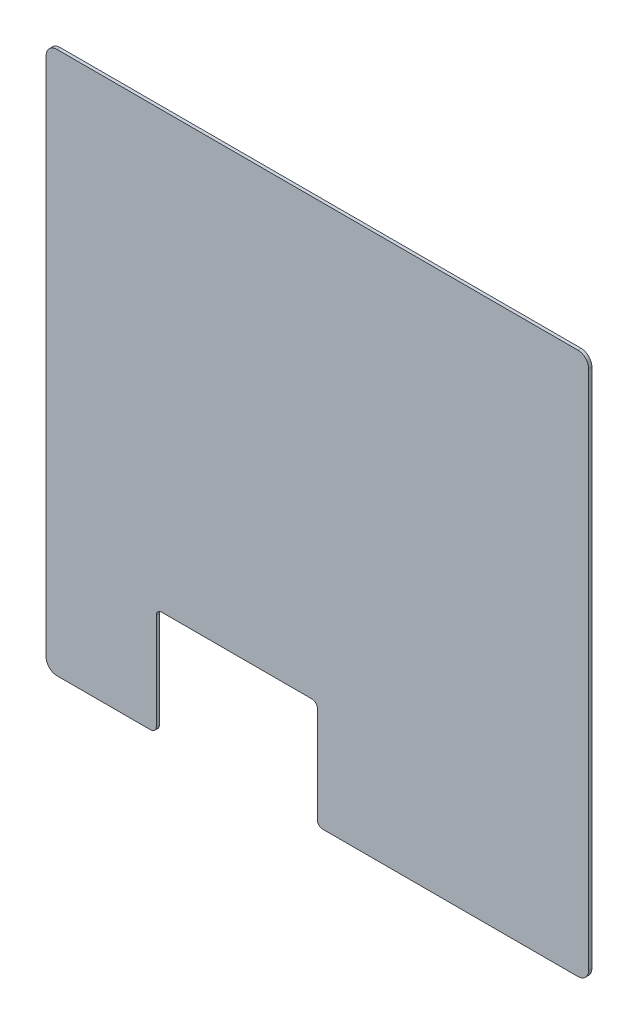
from build123d import *

# Parameters (mm, degrees)
SKETCH1_W           = 1010
SKETCH1_H           = 1010
BOSS_EXTRUDE1_DEPTH = 6
SKETCH2_W           = 300
SKETCH2_H           = 200
CUT_EXTRUDE1_DEPTH  = 6
FILLET2_R           = 20
FILLET3_R           = 10


with BuildPart() as part:
    # Sketch1 → Boss-Extrude1 (new body)
    with BuildSketch(Plane.XY):
        Rectangle(SKETCH1_W, SKETCH1_H)
    extrude(amount=BOSS_EXTRUDE1_DEPTH)

    # Sketch2 → Cut-Extrude1 (cut)
    with BuildSketch(Plane.XY.offset(6)):
        with Locations((-150, -405)):
            Rectangle(SKETCH2_W, SKETCH2_H)
    extrude(amount=-CUT_EXTRUDE1_DEPTH, mode=Mode.SUBTRACT)

    # Fillet2
    fillet2_edges = [part.edges().sort_by_distance(p)[0] for p in [
        (-505, 505, 3),
        (505, 505, 3),
        (505, -505, 3),
        (-505, -505, 3),
    ]]
    fillet(fillet2_edges, radius=FILLET2_R)

    # Fillet3
    fillet3_edges = [part.edges().sort_by_distance(p)[0] for p in [
        (-300, -505, 3),
        (-300, -305, 3),
        (0, -305, 3),
        (0, -505, 3),
    ]]
    fillet(fillet3_edges, radius=FILLET3_R)


solid = part.part
